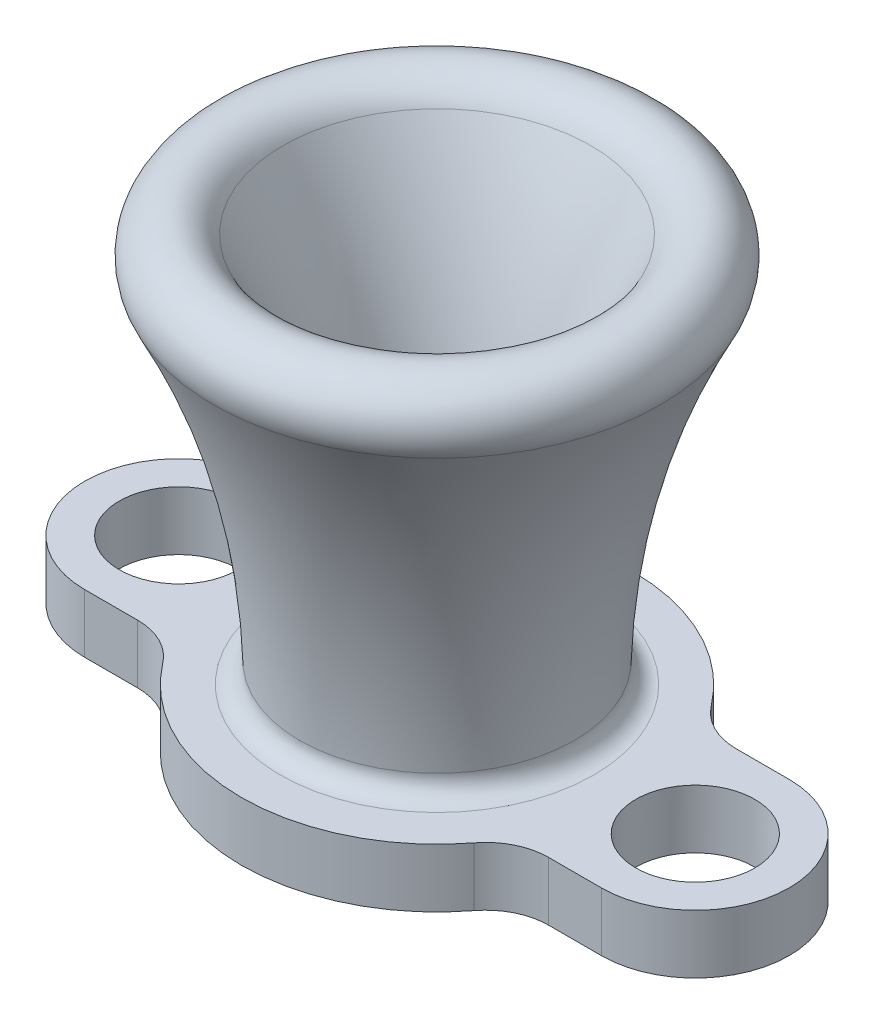
from build123d import *

# Parameters (mm, degrees)
SKETCH2_OUTSIDE_W  = 39.511
SKETCH2_OUTSIDE_H  = 39.51
SKETCH2_OUTSIDE_R  = 2.413
CUT_EXTRUDE1_DEPTH = 2.38125
FILLET1_R          = 2.54
FILLET2_R          = 0.79375


with BuildPart() as part:
    # Sketch1 → Revolve1 (revolve)
    with BuildSketch(Plane.XY):
        with BuildLine():
            Line((-5.55625, 0), (-14.2875, 0))
            Line((-14.2875, 0), (-14.2875, -2.38125))
            Line((-14.2875, -2.38125), (-2.38125, -2.38125))
            Line((-2.38125, -2.38125), (-2.38125, 0))
            ThreePointArc((-2.38125, 0), (-3.359821243, 8.138211612), (-6.239746425, 15.812462121))
            ThreePointArc((-6.239746425, 15.812462121), (-8.380030966, 16.49032242), (-9.057891265, 14.350037879))
            ThreePointArc((-9.057891265, 14.350037879), (-6.444317544, 7.385544643), (-5.55625, 0))
        make_face()
    revolve(axis=Axis((0, -2.38125, 0), (0, 1, 0)))

    # Sketch2 outside → Cut-Extrude1 (cut)
    with BuildSketch(Plane.XZ.offset(2.38125)):
        with Locations((0.0005, 0)):
            Rectangle(SKETCH2_OUTSIDE_W, SKETCH2_OUTSIDE_H)
        with BuildLine():
            Line((-10.4775, 3.81), (-6.963318623, 3.81))
            ThreePointArc((-6.963318623, 3.81), (0, 7.9375), (6.963318623, 3.81))
            Line((6.963318623, 3.81), (10.4775, 3.81))
            ThreePointArc((10.4775, 3.81), (14.2875, 0), (10.4775, -3.81))
            Line((10.4775, -3.81), (6.963318623, -3.81))
            ThreePointArc((6.963318623, -3.81), (0, -7.9375), (-6.963318623, -3.81))
            Line((-6.963318623, -3.81), (-10.4775, -3.81))
            ThreePointArc((-10.4775, -3.81), (-14.2875, 0), (-10.4775, 3.81))
        make_face(mode=Mode.SUBTRACT)
        with Locations((-10.4775, 0)):
            Circle(SKETCH2_OUTSIDE_R)
        with Locations((10.4775, 0)):
            Circle(SKETCH2_OUTSIDE_R)
    extrude(amount=-CUT_EXTRUDE1_DEPTH, mode=Mode.SUBTRACT)

    # Fillet1
    fillet1_edges = [part.edges().sort_by_distance(p)[0] for p in [
        (-6.963318623, -1.190625, -3.81),
        (6.963318623, -1.190625, -3.81),
        (6.963318623, -1.190625, 3.81),
        (-6.963318623, -1.190625, 3.81),
    ]]
    fillet(fillet1_edges, radius=FILLET1_R)

    # Fillet2
    fillet2_edges = [part.edges().sort_by_distance(p)[0] for p in [
        (5.55625, 0, 0),
    ]]
    fillet(fillet2_edges, radius=FILLET2_R)


solid = part.part
